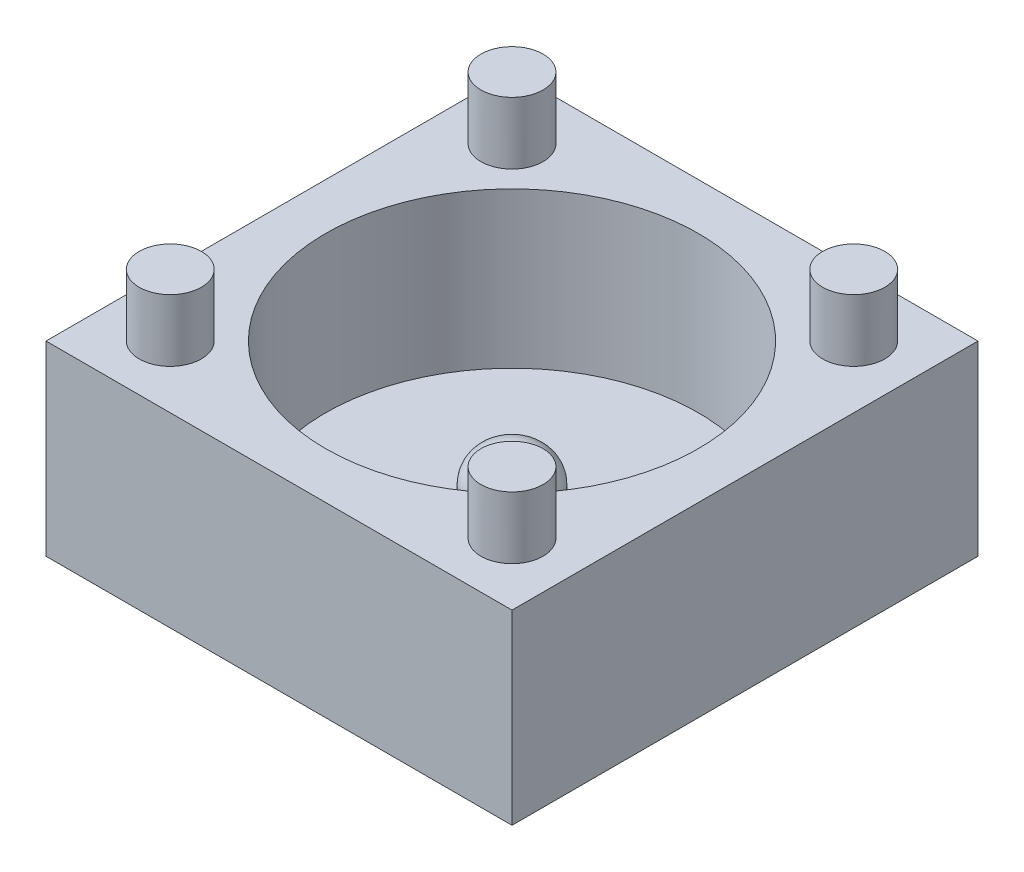
from build123d import *

# Parameters (mm, degrees)
SKETCH1_W           = 15
SKETCH1_H           = 15
BOSS_EXTRUDE1_DEPTH = 6
SKETCH2_R           = 6
CUT_EXTRUDE1_DEPTH  = 5
SKETCH3_R           = 1.25
BOSS_EXTRUDE2_DEPTH = 2
FILLET1_R           = 1
SKETCH4_R           = 1
BOSS_EXTRUDE3_DEPTH = 2


with BuildPart() as part:
    # Sketch1 → Boss-Extrude1 (new body)
    with BuildSketch(Plane(origin=(0, 0, 0), x_dir=(1, 0, 0), z_dir=(0, 1, 0))):
        Rectangle(SKETCH1_W, SKETCH1_H)
    extrude(amount=BOSS_EXTRUDE1_DEPTH)

    # Sketch2 → Cut-Extrude1 (cut)
    with BuildSketch(Plane(origin=(0, 6, 0), x_dir=(1, 0, 0), z_dir=(0, 1, 0))):
        Circle(SKETCH2_R)
    extrude(amount=-CUT_EXTRUDE1_DEPTH, mode=Mode.SUBTRACT)

    # Sketch3 → Boss-Extrude2 (add)
    with BuildSketch(Plane(origin=(0, 1, 0), x_dir=(1, 0, 0), z_dir=(0, 1, 0))):
        Circle(SKETCH3_R)
    extrude(amount=BOSS_EXTRUDE2_DEPTH)

    # Fillet1
    fillet1_edges = [part.edges().sort_by_distance(p)[0] for p in [
        (-1.25, 3, 0),
    ]]
    fillet(fillet1_edges, radius=FILLET1_R)

    # Sketch4 → Boss-Extrude3 (add)
    with BuildSketch(Plane(origin=(0, 6, 0), x_dir=(1, 0, 0), z_dir=(0, 1, 0))):
        with Locations((-5.5, 5.5)):
            Circle(SKETCH4_R)
        with Locations((5.5, 5.5)):
            Circle(SKETCH4_R)
        with Locations((-5.5, -5.5)):
            Circle(SKETCH4_R)
        with Locations((5.5, -5.5)):
            Circle(SKETCH4_R)
    extrude(amount=BOSS_EXTRUDE3_DEPTH)


solid = part.part
